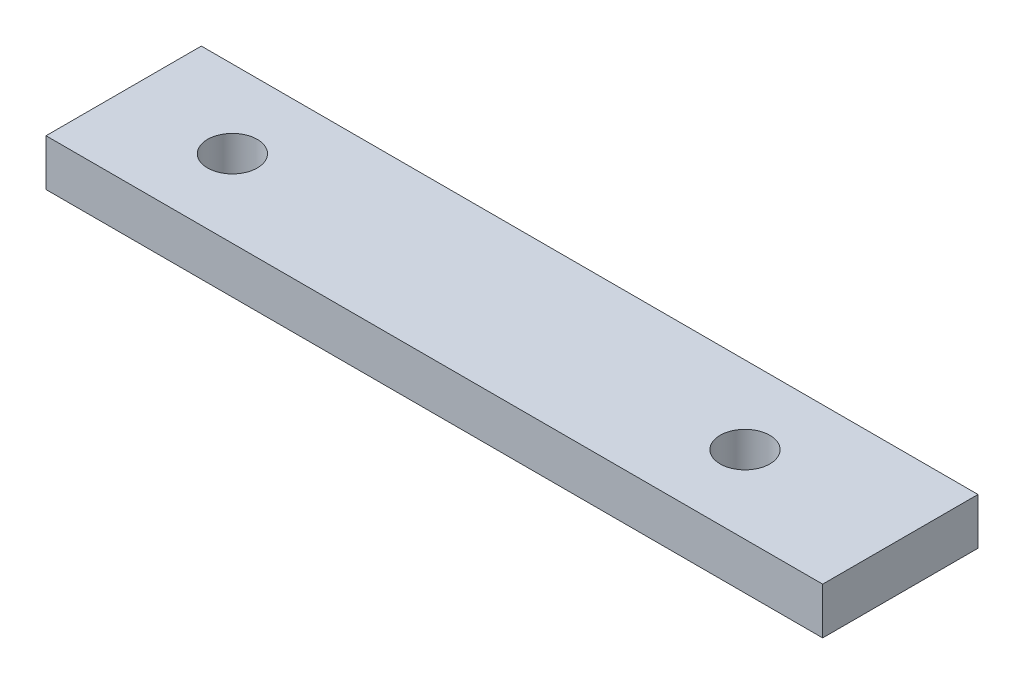
from build123d import *

# Parameters (mm, degrees)
SKETCH1_W           = 50
SKETCH1_H           = 10
SKETCH1_R           = 1.6
BOSS_EXTRUDE1_DEPTH = 3


with BuildPart() as part:
    # Sketch1 → Boss-Extrude1 (new body)
    with BuildSketch(Plane(origin=(0, 0, 0), x_dir=(1, 0, 0), z_dir=(0, 1, 0))):
        with Locations((25, 5)):
            Rectangle(SKETCH1_W, SKETCH1_H)
        with Locations((7, 5)):
            Circle(SKETCH1_R, mode=Mode.SUBTRACT)
        with Locations((40, 5)):
            Circle(SKETCH1_R, mode=Mode.SUBTRACT)
    extrude(amount=BOSS_EXTRUDE1_DEPTH)


solid = part.part
